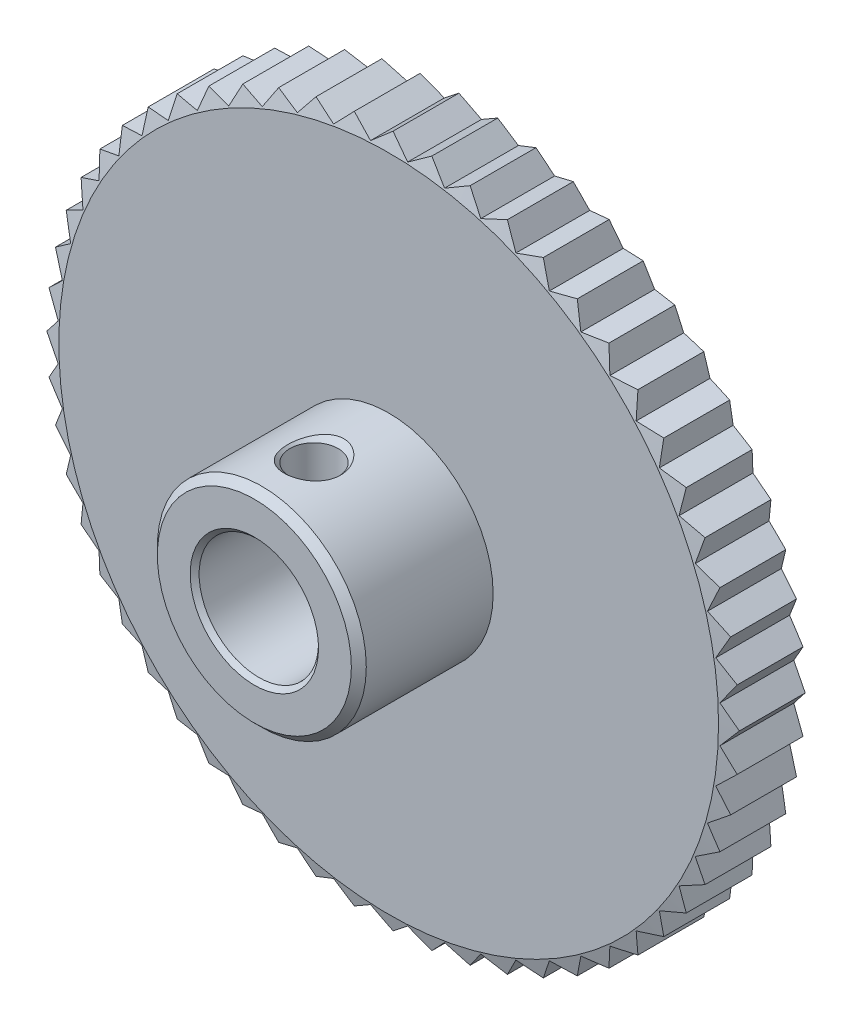
from build123d import *

# Parameters (mm, degrees)
SKETCH2_R          = 46.4
CUT_EXTRUDE1_DEPTH = 5


with BuildPart() as part:
    # Sketch1 → Revolve1 (revolve)
    with BuildSketch(Plane(origin=(0, 0, 0), x_dir=(0, 0, -1), z_dir=(1, 0, 0))):
        Polygon((-14, 4.3), (-13.7, 4), (-0.3, 4), (0, 4.3), (0, 22.1), (-0.562693304, 24.2), (-4.437306696, 24.2), (-5, 22.1), (-5, 7), (-13.5, 7), (-14, 6.5), align=None)
    revolve(axis=Axis((0, 0, 0), (0, 0, 1)))

    # Sketch2 → Cut-Extrude1 (cut)
    with BuildSketch(Plane.XY):
        Circle(SKETCH2_R)
        Polygon((-23.2, 0), (-22.165075293, -1.244763929), (-23.05412327, -2.597575846), (-21.886336611, -3.718638157), (-22.618327563, -5.162485668), (-21.332364547, -6.145748354), (-21.898093263, -7.662474237), (-20.510125622, -8.495572199), (-20.902477735, -10.066102748), (-19.429959966, -10.738559294), (-19.644001422, -12.343144175), (-18.105451291, -12.846502775), (-18.138490393, -14.464963403), (-16.55325606, -14.792894031), (-16.404877324, -16.404877324), (-14.792894031, -16.55325606), (-14.464963403, -18.138490393), (-12.846502775, -18.105451291), (-12.343144175, -19.644001422), (-10.738559294, -19.429959966), (-10.066102748, -20.902477735), (-8.495572199, -20.510125622), (-7.662474237, -21.898093263), (-6.145748354, -21.332364547), (-5.162485668, -22.618327563), (-3.718638157, -21.886336611), (-2.597575846, -23.05412327), (-1.244763929, -22.165075293), (0, -23.2), (1.244763929, -22.165075293), (2.597575846, -23.05412327), (3.718638157, -21.886336611), (5.162485668, -22.618327563), (6.145748354, -21.332364547), (7.662474237, -21.898093263), (8.495572199, -20.510125622), (10.066102748, -20.902477735), (10.738559294, -19.429959966), (12.343144175, -19.644001422), (12.846502775, -18.105451291), (14.464963403, -18.138490393), (14.792894031, -16.55325606), (16.404877324, -16.404877324), (16.55325606, -14.792894031), (18.138490393, -14.464963403), (18.105451291, -12.846502775), (19.644001422, -12.343144175), (19.429959966, -10.738559294), (20.902477735, -10.066102748), (20.510125622, -8.495572199), (21.898093263, -7.662474237), (21.332364547, -6.145748354), (22.618327563, -5.162485668), (21.886336611, -3.718638157), (23.05412327, -2.597575846), (22.165075293, -1.244763929), (23.2, 0), (22.165075293, 1.244763929), (23.05412327, 2.597575846), (21.886336611, 3.718638157), (22.618327563, 5.162485668), (21.332364547, 6.145748354), (21.898093263, 7.662474237), (20.510125622, 8.495572199), (20.902477735, 10.066102748), (19.429959966, 10.738559294), (19.644001422, 12.343144175), (18.105451291, 12.846502775), (18.138490393, 14.464963403), (16.55325606, 14.792894031), (16.404877324, 16.404877324), (14.792894031, 16.55325606), (14.464963403, 18.138490393), (12.846502775, 18.105451291), (12.343144175, 19.644001422), (10.738559294, 19.429959966), (10.066102748, 20.902477735), (8.495572199, 20.510125622), (7.662474237, 21.898093263), (6.145748354, 21.332364547), (5.162485668, 22.618327563), (3.718638157, 21.886336611), (2.597575846, 23.05412327), (1.244763929, 22.165075293), (0, 23.2), (-1.244763929, 22.165075293), (-2.597575846, 23.05412327), (-3.718638157, 21.886336611), (-5.162485668, 22.618327563), (-6.145748354, 21.332364547), (-7.662474237, 21.898093263), (-8.495572199, 20.510125622), (-10.066102748, 20.902477735), (-10.738559294, 19.429959966), (-12.343144175, 19.644001422), (-12.846502775, 18.105451291), (-14.464963403, 18.138490393), (-14.792894031, 16.55325606), (-16.404877324, 16.404877324), (-16.55325606, 14.792894031), (-18.138490393, 14.464963403), (-18.105451291, 12.846502775), (-19.644001422, 12.343144175), (-19.429959966, 10.738559294), (-20.902477735, 10.066102748), (-20.510125622, 8.495572199), (-21.898093263, 7.662474237), (-21.332364547, 6.145748354), (-22.618327563, 5.162485668), (-21.886336611, 3.718638157), (-23.05412327, 2.597575846), (-22.165075293, 1.244763929), align=None, mode=Mode.SUBTRACT)
    extrude(amount=CUT_EXTRUDE1_DEPTH, mode=Mode.SUBTRACT)

    # Sketch3 → Cut-Revolve1 (revolve, cut)
    with BuildSketch(Plane.XY.offset(10)):
        Polygon((0, 0), (-2, 0), (-2, 4), (-1.621, 4.379), (-1.621, 6.621), (-2, 7), (-2, 15), (0, 15), align=None)
    revolve(axis=Axis((0, 15, 10), (0, -1, 0)), mode=Mode.SUBTRACT)


solid = part.part
